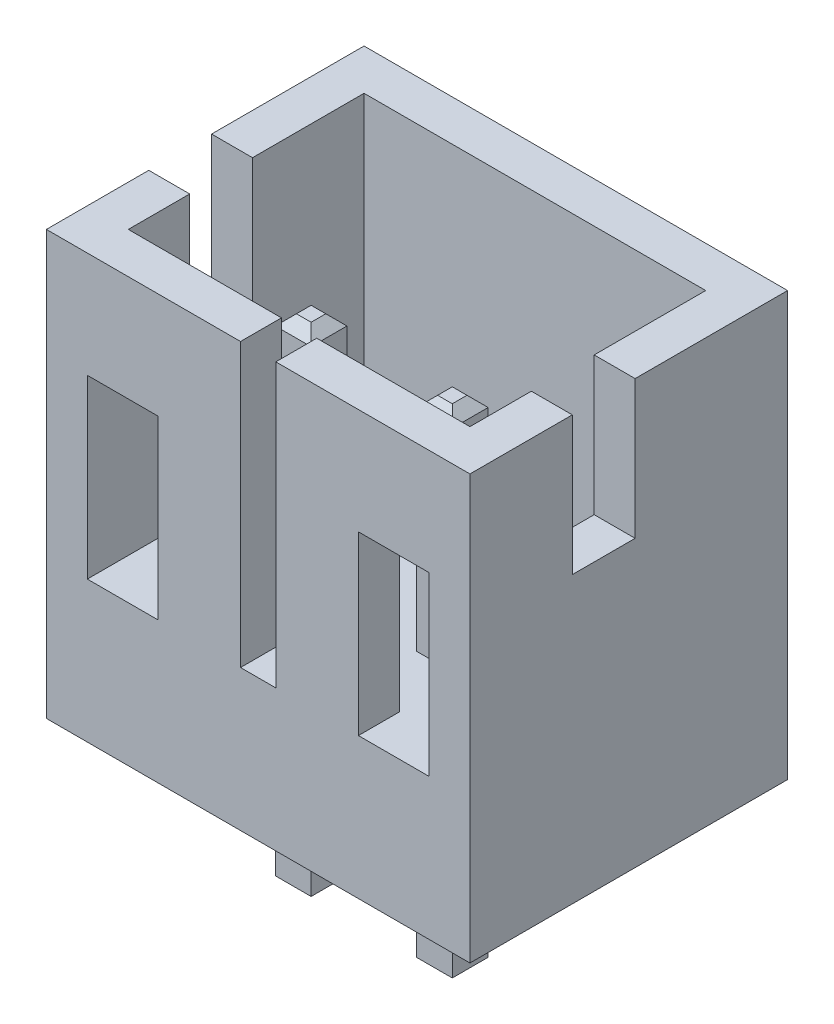
from build123d import *

# Parameters (mm, degrees)
SKETCH4_W                          = 6
SKETCH4_H                          = 4.5
BODY_EXTRUDE2_DEPTH                = 6
BODY_SHELL1_T                      = -0.58
BODY_SHELL1_THICKNESS_2_FACE_W     = 3.34
BODY_SHELL1_THICKNESS_2_FACE_H     = 4.84
BODY_SHELL1_THICKNESS_2_DEPTH      = 1.42
EXTRUDE3_REACH                     = 9.075
SKETCH66_W                         = 0.89
SKETCH66_H                         = 1.96
EXTRUDE3_DIRECTION_2_REACH         = 9.075
EXTRUDE2_REACH                     = 9.77
SKETCH65_W                         = 0.5
SKETCH65_H                         = 4
SKETCH65_W_2                       = 1
SKETCH65_H_2                       = 2.5
SKETCH64_W                         = 0.508
SKETCH64_H                         = 0.508
PINS_EXTRUDE_DEPTH                 = 7.045
PINS_CHAMFER_SIZE                  = 0.15
PINS_LPATTERN_COUNT                = 2
PINS_LPATTERN_PITCH                = 2
PINS_CHAMFER_OF_PINS_LPATTERN_SIZE = 0.15


with BuildPart() as part:
    # Sketch4 → Body-Extrude2 (new body)
    with BuildSketch(Plane(origin=(6.86422654, 0, 1.863703399), x_dir=(1, 0, 0), z_dir=(0, 1, 0))):
        with Locations((-6.86422654, 1.863703399)):
            Rectangle(SKETCH4_W, SKETCH4_H)
    extrude(amount=BODY_EXTRUDE2_DEPTH)

    # Body-Shell1
    body_shell1_openings = [part.faces().sort_by_distance(p)[0] for p in [
        (0, 6, 0),
    ]]
    offset(amount=BODY_SHELL1_T, openings=body_shell1_openings, kind=Kind.INTERSECTION)

    # Body-Shell1 thickness 2 face (on inner face of the shell) → Body-Shell1 thickness 2 (add)
    with BuildSketch(Plane(origin=(0, 0.58, 0), x_dir=(0, 0, -1), z_dir=(0, -1, 0))):
        Rectangle(BODY_SHELL1_THICKNESS_2_FACE_W, BODY_SHELL1_THICKNESS_2_FACE_H)
    extrude(amount=-BODY_SHELL1_THICKNESS_2_DEPTH)

    # Extrude3: up to this face of the body (flat: up to its plane)
    extrude3_end = Plane(part.part.faces().sort_by_distance((-3, 3, 0))[0])
    # Sketch66 → Extrude3 (cut, up to the picked face)
    with BuildSketch(Plane(origin=(0, 0, 0), x_dir=(0, 0, -1), z_dir=(1, 0, 0)), mode=Mode.PRIVATE) as extrude3_sk1:
        with Locations((-0.355, 5.02)):
            Rectangle(SKETCH66_W, SKETCH66_H)
    extrude3_tool1 = split(extrude(extrude3_sk1.sketch, amount=-EXTRUDE3_REACH, mode=Mode.PRIVATE), bisect_by=extrude3_end, keep=Keep.BOTH, mode=Mode.PRIVATE)
    add(extrude3_tool1.solids().sort_by(Axis((0, 5.02, 0.355), (-1, 0, 0)))[0], mode=Mode.SUBTRACT)

    # Extrude3 direction 2: up to this face of the body (flat: up to its plane)
    extrude3_direction_2_end = Plane(part.part.faces().sort_by_distance((3, 3, 0))[0])
    # Sketch66 → Extrude3 direction 2 (cut, up to the picked face)
    with BuildSketch(Plane(origin=(0, 0, 0), x_dir=(0, 0, -1), z_dir=(1, 0, 0)), mode=Mode.PRIVATE) as extrude3_direction_2_sk1:
        with Locations((-0.355, 5.02)):
            Rectangle(SKETCH66_W, SKETCH66_H)
    extrude3_direction_2_tool1 = split(extrude(extrude3_direction_2_sk1.sketch, amount=EXTRUDE3_DIRECTION_2_REACH, mode=Mode.PRIVATE), bisect_by=extrude3_direction_2_end, keep=Keep.BOTH, mode=Mode.PRIVATE)
    add(extrude3_direction_2_tool1.solids().sort_by(Axis((0, 5.02, 0.355), (1, 0, 0)))[0], mode=Mode.SUBTRACT)

    # Sketch65 → Extrude2 (cut, up to next)
    with BuildSketch(Plane(origin=(0, 0, 1.67), x_dir=(1, 0, 0), z_dir=(0, 0, -1)), mode=Mode.PRIVATE) as extrude2_sk1:
        with Locations((0, -4)):
            Rectangle(SKETCH65_W, SKETCH65_H)
    extrude2_tool1 = extrude(extrude2_sk1.sketch, amount=-EXTRUDE2_REACH, mode=Mode.PRIVATE) & part.part
    # Sketch65 → Extrude2 (cut, up to next)
    with BuildSketch(Plane(origin=(0, 0, 1.67), x_dir=(1, 0, 0), z_dir=(0, 0, -1)), mode=Mode.PRIVATE) as extrude2_sk2:
        with Locations((-1.92, -3.25)):
            Rectangle(SKETCH65_W_2, SKETCH65_H_2)
    extrude2_tool2 = extrude(extrude2_sk2.sketch, amount=-EXTRUDE2_REACH, mode=Mode.PRIVATE) & part.part
    # Sketch65 → Extrude2 (cut, up to next)
    with BuildSketch(Plane(origin=(0, 0, 1.67), x_dir=(1, 0, 0), z_dir=(0, 0, -1)), mode=Mode.PRIVATE) as extrude2_sk3:
        with Locations((1.92, -3.25)):
            Rectangle(SKETCH65_W_2, SKETCH65_H_2)
    extrude2_tool3 = extrude(extrude2_sk3.sketch, amount=-EXTRUDE2_REACH, mode=Mode.PRIVATE) & part.part
    add(extrude2_tool1.solids().sort_by_distance((0, 4, 1.67))[0], mode=Mode.SUBTRACT)
    add(extrude2_tool2.solids().sort_by_distance((-1.92, 3.25, 1.67))[0], mode=Mode.SUBTRACT)
    add(extrude2_tool3.solids().sort_by_distance((1.92, 3.25, 1.67))[0], mode=Mode.SUBTRACT)

    # Sketch64 → Pins-Extrude (add)
    with BuildSketch(Plane(origin=(0, 5.14, -3.64), x_dir=(1, 0, 0), z_dir=(0, -1, 0))):
        with Locations((1.05, 4.19)):
            Rectangle(SKETCH64_W, SKETCH64_H)
    pins_extrude = extrude(amount=PINS_EXTRUDE_DEPTH)

    # Pins-Chamfer
    pins_chamfer_edges = [part.edges().sort_by_distance(p)[0] for p in [
        (0.796, 5.14, 0.55),
        (1.05, 5.14, 0.296),
        (1.304, 5.14, 0.55),
        (1.05, 5.14, 0.804),
        (1.05, -1.905, 0.804),
        (0.796, -1.905, 0.55),
        (1.05, -1.905, 0.296),
        (1.304, -1.905, 0.55),
    ]]
    chamfer(pins_chamfer_edges, length=PINS_CHAMFER_SIZE)

    # Pins-LPattern: Pins-Extrude ×2
    with Locations(*[(-i * PINS_LPATTERN_PITCH, 0, 0) for i in range(1, PINS_LPATTERN_COUNT)]):
        add(pins_extrude)

    # Pins-Chamfer of Pins-LPattern
    pins_chamfer_of_pins_lpattern_edges = [part.edges().sort_by_distance(p)[0] for p in [
        (-1.204, 5.14, 0.55),
        (-0.95, 5.14, 0.296),
        (-0.696, 5.14, 0.55),
        (-0.95, 5.14, 0.804),
        (-0.95, -1.905, 0.804),
        (-1.204, -1.905, 0.55),
        (-0.95, -1.905, 0.296),
        (-0.696, -1.905, 0.55),
    ]]
    chamfer(pins_chamfer_of_pins_lpattern_edges, length=PINS_CHAMFER_OF_PINS_LPATTERN_SIZE)


solid = part.part
